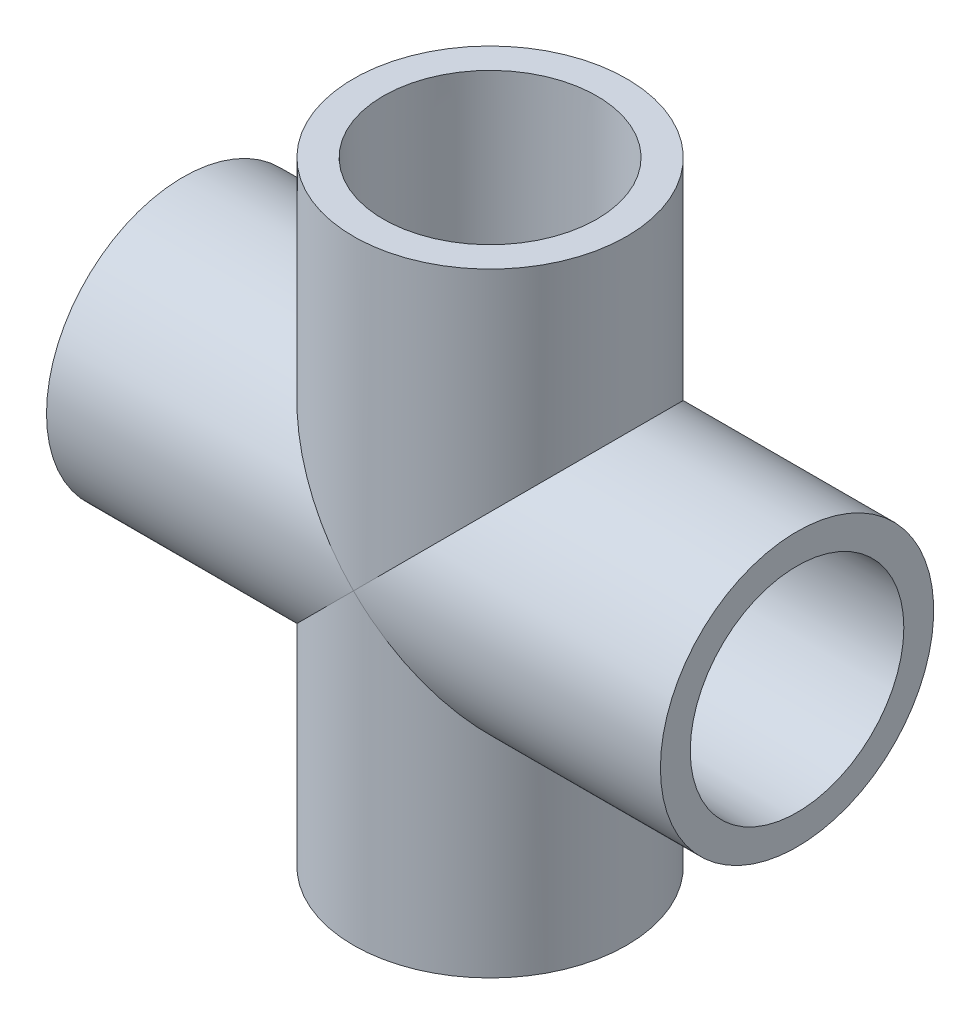
from build123d import *

# Parameters (mm, degrees)
SKETCH4_R           = 13.7795
BOSS_EXTRUDE1_DEPTH = 44.45
SKETCH5_R           = 13.7795
BOSS_EXTRUDE2_DEPTH = 44.45


with BuildPart() as part:
    # Sketch1 → Revolve1 (revolve)
    with BuildSketch(Plane.XY):
        Polygon((-30.95625, -13.7795), (-13.49375, -13.7795), (-13.49375, -10.6172), (-30.95625, -10.7696), align=None)
        Polygon((30.95625, -10.7696), (13.49375, -10.6172), (13.49375, -13.7795), (30.95625, -13.7795), align=None)
    revolve(axis=Axis((-30.95625, 0, 0), (1, 0, 0)))



with BuildPart() as body_2:
    # Sketch2 → Revolve2 (revolve)
    with BuildSketch(Plane.XY):
        Polygon((10.7696, 30.95625), (10.6172, 13.49375), (13.7795, 13.49375), (13.7795, 30.95625), align=None)
        Polygon((13.7795, -30.95625), (10.7696, -30.95625), (10.6172, -13.49375), (13.7795, -13.49375), align=None)
    revolve(axis=Axis((0, 0, 0), (0, 1, 0)))


with BuildPart() as part_1:
    add(part.part)

    add(body_2.part)  # Boss-Extrude1 merges body 2
    # Sketch4 → Boss-Extrude1 (add)
    with BuildSketch(Plane(origin=(-13.49375, 0, 0), x_dir=(0, 0, -1), z_dir=(1, 0, 0))):
        Circle(SKETCH4_R)
    extrude(amount=BOSS_EXTRUDE1_DEPTH)

    # Sketch5 → Boss-Extrude2 (add)
    with BuildSketch(Plane.XZ.offset(-13.49375)):
        Circle(SKETCH5_R)
    extrude(amount=BOSS_EXTRUDE2_DEPTH)

    # Sketch6 → Cut-Revolve1 (revolve, cut)
    with BuildSketch(Plane.XY):
        Polygon((-30.95625, -10.7696), (-13.49375, -10.6172), (-13.49375, -7.8994), (13.49375, -7.8994), (13.49375, -10.6172), (30.95625, -10.7696), (30.95625, 0), (-30.95625, 0), align=None)
    revolve(axis=Axis((30.95625, 0, 0), (-1, 0, 0)), mode=Mode.SUBTRACT)

    # Sketch7 → Cut-Revolve2 (revolve, cut)
    with BuildSketch(Plane.XY):
        Polygon((10.7696, 30.95625), (10.6172, 13.49375), (7.8994, 13.49375), (7.8994, -13.49375), (10.6172, -13.49375), (10.7696, -30.95625), (0, -30.95625), (0, 30.95625), align=None)
    revolve(axis=Axis((0, 30.95625, 0), (0, -1, 0)), mode=Mode.SUBTRACT)


solid = part_1.part
